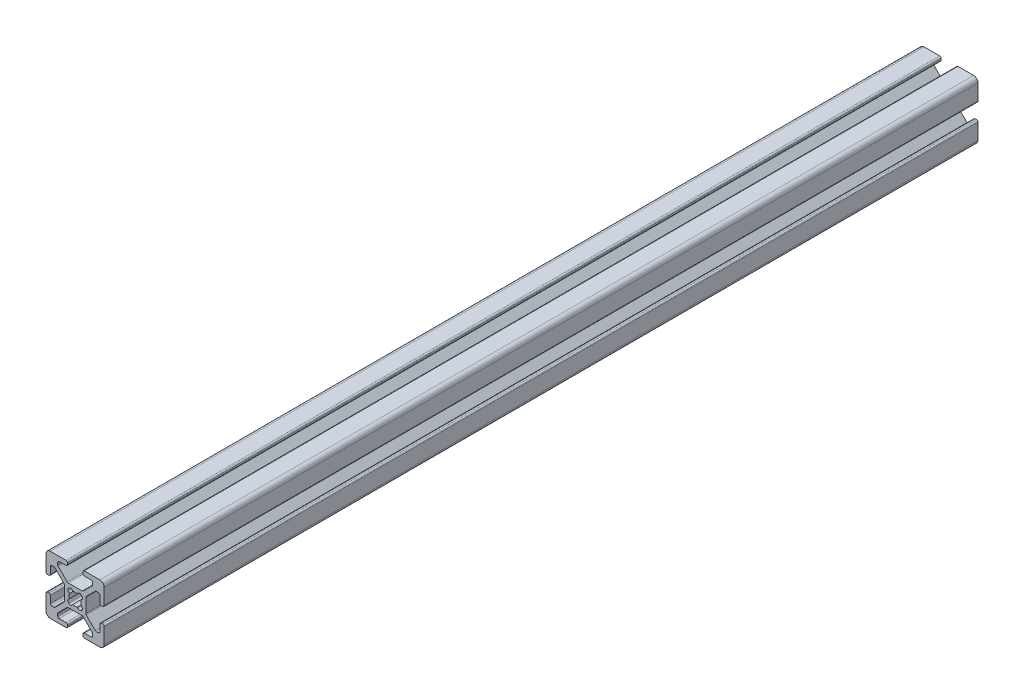
from build123d import *

# Parameters (mm, degrees)
EXTRUDE1_DEPTH = 300


with BuildPart() as part:
    # Sketch1 → Extrude1 (new body)
    with BuildSketch(Plane.XY):
        with BuildLine():
            Line((-5.032287798, -0.341059771), (-5.516287798, -0.341059771))
            ThreePointArc((-5.516287798, -0.341059771), (-5.875498042, -0.192270016), (-6.024287798, 0.166940229))
            Line((-6.024287798, 0.166940229), (-6.024287798, 2.515940229))
            ThreePointArc((-6.024287798, 2.515940229), (-6.173077553, 2.875150474), (-6.532287798, 3.023940229))
            Line((-6.532287798, 3.023940229), (-7.258207136, 3.023940229))
            ThreePointArc((-7.258207136, 3.023940229), (-7.45261032, 2.985271032), (-7.617417381, 2.875150474))
            Line((-7.617417381, 2.875150474), (-10.720498042, -0.227930187))
            ThreePointArc((-10.720498042, -0.227930187), (-10.8306186, -0.392737249), (-10.869287798, -0.587140432))
            Line((-10.869287798, -0.587140432), (-10.869287798, -5.354979109))
            ThreePointArc((-10.869287798, -5.354979109), (-10.8306186, -5.549382293), (-10.720498042, -5.714189354))
            Line((-10.720498042, -5.714189354), (-7.617417381, -8.817270016))
            ThreePointArc((-7.617417381, -8.817270016), (-7.45261032, -8.927390573), (-7.258207136, -8.966059771))
            Line((-7.258207136, -8.966059771), (-6.532287798, -8.966059771))
            ThreePointArc((-6.532287798, -8.966059771), (-6.173077553, -8.817270016), (-6.024287798, -8.458059771))
            Line((-6.024287798, -8.458059771), (-6.024287798, -6.109059771))
            ThreePointArc((-6.024287798, -6.109059771), (-5.875498042, -5.749849526), (-5.516287798, -5.601059771))
            Line((-5.516287798, -5.601059771), (-5.032287798, -5.601059771))
            ThreePointArc((-5.032287798, -5.601059771), (-4.673077553, -5.749849526), (-4.524287798, -6.109059771))
            Line((-4.524287798, -6.109059771), (-4.524287798, -11.471059771))
            ThreePointArc((-4.524287798, -11.471059771), (-4.963627626, -12.531719943), (-6.024287798, -12.971059771))
            Line((-6.024287798, -12.971059771), (-11.386287798, -12.971059771))
            ThreePointArc((-11.386287798, -12.971059771), (-11.745498042, -12.822270016), (-11.894287798, -12.463059771))
            Line((-11.894287798, -12.463059771), (-11.894287798, -11.979059771))
            ThreePointArc((-11.894287798, -11.979059771), (-11.745498042, -11.619849526), (-11.386287798, -11.471059771))
            Line((-11.386287798, -11.471059771), (-9.037287798, -11.471059771))
            ThreePointArc((-9.037287798, -11.471059771), (-8.678077553, -11.322270016), (-8.529287798, -10.963059771))
            Line((-8.529287798, -10.963059771), (-8.529287798, -10.237140432))
            ThreePointArc((-8.529287798, -10.237140432), (-8.567956995, -10.042737249), (-8.678077553, -9.877930187))
            Line((-8.678077553, -9.877930187), (-11.781158214, -6.774849526))
            ThreePointArc((-11.781158214, -6.774849526), (-11.945965275, -6.664728968), (-12.140368459, -6.626059771))
            Line((-12.140368459, -6.626059771), (-16.908207136, -6.626059771))
            ThreePointArc((-16.908207136, -6.626059771), (-17.10261032, -6.664728968), (-17.267417381, -6.774849526))
            Line((-17.267417381, -6.774849526), (-20.370498042, -9.877930187))
            ThreePointArc((-20.370498042, -9.877930187), (-20.4806186, -10.042737249), (-20.519287798, -10.237140432))
            Line((-20.519287798, -10.237140432), (-20.519287798, -10.963059771))
            ThreePointArc((-20.519287798, -10.963059771), (-20.370498042, -11.322270016), (-20.011287798, -11.471059771))
            Line((-20.011287798, -11.471059771), (-17.662287798, -11.471059771))
            ThreePointArc((-17.662287798, -11.471059771), (-17.303077553, -11.619849526), (-17.154287798, -11.979059771))
            Line((-17.154287798, -11.979059771), (-17.154287798, -12.463059771))
            ThreePointArc((-17.154287798, -12.463059771), (-17.303077553, -12.822270016), (-17.662287798, -12.971059771))
            Line((-17.662287798, -12.971059771), (-23.024287798, -12.971059771))
            ThreePointArc((-23.024287798, -12.971059771), (-24.084947969, -12.531719943), (-24.524287798, -11.471059771))
            Line((-24.524287798, -11.471059771), (-24.524287798, -6.109059771))
            ThreePointArc((-24.524287798, -6.109059771), (-24.375498042, -5.749849526), (-24.016287798, -5.601059771))
            Line((-24.016287798, -5.601059771), (-23.532287798, -5.601059771))
            ThreePointArc((-23.532287798, -5.601059771), (-23.173077553, -5.749849526), (-23.024287798, -6.109059771))
            Line((-23.024287798, -6.109059771), (-23.024287798, -8.458059771))
            ThreePointArc((-23.024287798, -8.458059771), (-22.875498042, -8.817270016), (-22.516287798, -8.966059771))
            Line((-22.516287798, -8.966059771), (-21.790368459, -8.966059771))
            ThreePointArc((-21.790368459, -8.966059771), (-21.595965275, -8.927390573), (-21.431158214, -8.817270016))
            Line((-21.431158214, -8.817270016), (-18.328077553, -5.714189354))
            ThreePointArc((-18.328077553, -5.714189354), (-18.217956995, -5.549382293), (-18.179287798, -5.354979109))
            Line((-18.179287798, -5.354979109), (-18.179287798, -0.587140432))
            ThreePointArc((-18.179287798, -0.587140432), (-18.217956995, -0.392737249), (-18.328077553, -0.227930187))
            Line((-18.328077553, -0.227930187), (-21.431158214, 2.875150474))
            ThreePointArc((-21.431158214, 2.875150474), (-21.595965275, 2.985271032), (-21.790368459, 3.023940229))
            Line((-21.790368459, 3.023940229), (-22.516287798, 3.023940229))
            ThreePointArc((-22.516287798, 3.023940229), (-22.875498042, 2.875150474), (-23.024287798, 2.515940229))
            Line((-23.024287798, 2.515940229), (-23.024287798, 0.166940229))
            ThreePointArc((-23.024287798, 0.166940229), (-23.173077553, -0.192270016), (-23.532287798, -0.341059771))
            Line((-23.532287798, -0.341059771), (-24.016287798, -0.341059771))
            ThreePointArc((-24.016287798, -0.341059771), (-24.375498042, -0.192270016), (-24.524287798, 0.166940229))
            Line((-24.524287798, 0.166940229), (-24.524287798, 5.528940229))
            ThreePointArc((-24.524287798, 5.528940229), (-24.084947969, 6.589600401), (-23.024287798, 7.028940229))
            Line((-23.024287798, 7.028940229), (-17.662287798, 7.028940229))
            ThreePointArc((-17.662287798, 7.028940229), (-17.303077553, 6.880150474), (-17.154287798, 6.520940229))
            Line((-17.154287798, 6.520940229), (-17.154287798, 6.036940229))
            ThreePointArc((-17.154287798, 6.036940229), (-17.303077553, 5.677729984), (-17.662287798, 5.528940229))
            Line((-17.662287798, 5.528940229), (-20.011287798, 5.528940229))
            ThreePointArc((-20.011287798, 5.528940229), (-20.370498042, 5.380150474), (-20.519287798, 5.020940229))
            Line((-20.519287798, 5.020940229), (-20.519287798, 4.295020891))
            ThreePointArc((-20.519287798, 4.295020891), (-20.4806186, 4.100617707), (-20.370498042, 3.935810646))
            Line((-20.370498042, 3.935810646), (-17.267417381, 0.832729984))
            ThreePointArc((-17.267417381, 0.832729984), (-17.10261032, 0.722609427), (-16.908207136, 0.683940229))
            Line((-16.908207136, 0.683940229), (-12.140368459, 0.683940229))
            ThreePointArc((-12.140368459, 0.683940229), (-11.945965275, 0.722609427), (-11.781158214, 0.832729984))
            Line((-11.781158214, 0.832729984), (-8.678077553, 3.935810646))
            ThreePointArc((-8.678077553, 3.935810646), (-8.567956995, 4.100617707), (-8.529287798, 4.295020891))
            Line((-8.529287798, 4.295020891), (-8.529287798, 5.020940229))
            ThreePointArc((-8.529287798, 5.020940229), (-8.678077553, 5.380150474), (-9.037287798, 5.528940229))
            Line((-9.037287798, 5.528940229), (-11.386287798, 5.528940229))
            ThreePointArc((-11.386287798, 5.528940229), (-11.745498042, 5.677729984), (-11.894287798, 6.036940229))
            Line((-11.894287798, 6.036940229), (-11.894287798, 6.520940229))
            ThreePointArc((-11.894287798, 6.520940229), (-11.745498042, 6.880150474), (-11.386287798, 7.028940229))
            Line((-11.386287798, 7.028940229), (-6.024287798, 7.028940229))
            ThreePointArc((-6.024287798, 7.028940229), (-4.963627626, 6.589600401), (-4.524287798, 5.528940229))
            Line((-4.524287798, 5.528940229), (-4.524287798, 0.166940229))
            ThreePointArc((-4.524287798, 0.166940229), (-4.673077553, -0.192270016), (-5.032287798, -0.341059771))
        make_face()
        with BuildLine():
            Line((-12.399386954, -5.275565737), (-12.219781831, -5.095960615))
            ThreePointArc((-12.219781831, -5.095960615), (-12.018349781, -4.327527582), (-12.589154291, -3.775036489))
            ThreePointArc((-12.589154291, -3.775036489), (-12.428787798, -2.971059771), (-12.589154291, -2.167083053))
            ThreePointArc((-12.589154291, -2.167083053), (-12.018349781, -1.61459196), (-12.219781831, -0.846158927))
            Line((-12.219781831, -0.846158927), (-12.399386954, -0.666553805))
            ThreePointArc((-12.399386954, -0.666553805), (-13.167819987, -0.465121754), (-13.72031108, -1.035926265))
            ThreePointArc((-13.72031108, -1.035926265), (-14.524287798, -0.875559771), (-15.328264516, -1.035926265))
            ThreePointArc((-15.328264516, -1.035926265), (-15.880755608, -0.465121754), (-16.649188641, -0.666553805))
            Line((-16.649188641, -0.666553805), (-16.828793764, -0.846158927))
            ThreePointArc((-16.828793764, -0.846158927), (-17.030225814, -1.61459196), (-16.459421304, -2.167083053))
            ThreePointArc((-16.459421304, -2.167083053), (-16.619787798, -2.971059771), (-16.459421304, -3.775036489))
            ThreePointArc((-16.459421304, -3.775036489), (-17.030225814, -4.327527582), (-16.828793764, -5.095960615))
            Line((-16.828793764, -5.095960615), (-16.649188641, -5.275565737))
            ThreePointArc((-16.649188641, -5.275565737), (-15.880755608, -5.476997788), (-15.328264516, -4.906193277))
            ThreePointArc((-15.328264516, -4.906193277), (-14.524287798, -5.066559771), (-13.72031108, -4.906193277))
            ThreePointArc((-13.72031108, -4.906193277), (-13.167819987, -5.476997788), (-12.399386954, -5.275565737))
        make_face(mode=Mode.SUBTRACT)
    extrude(amount=EXTRUDE1_DEPTH)


solid = part.part
